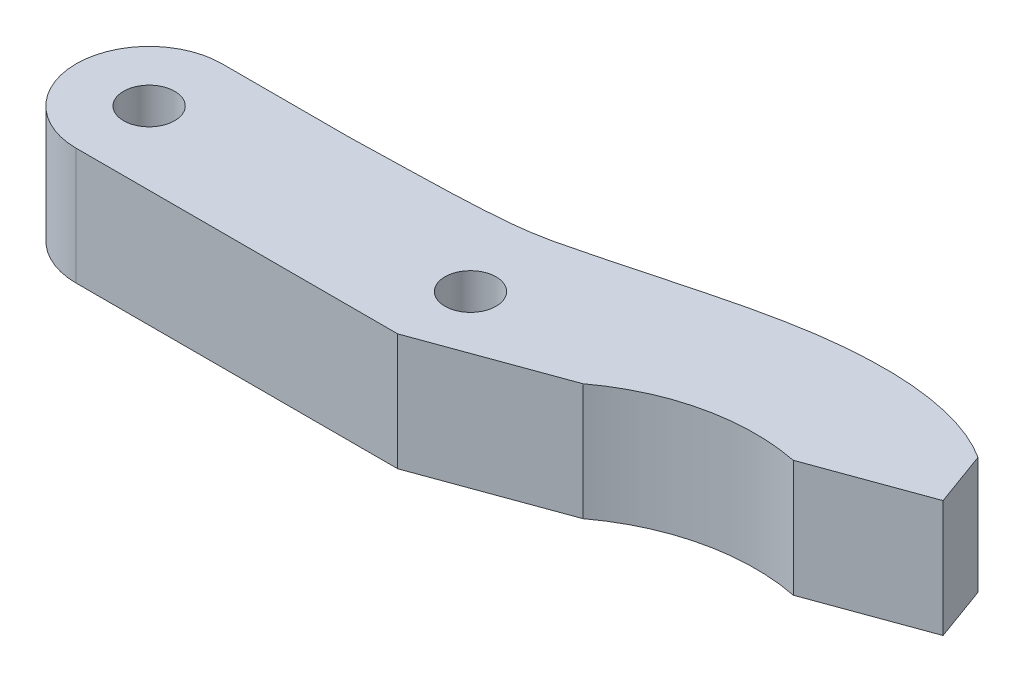
from build123d import *

# Parameters (mm, degrees)
IZIM1_R                     = 1.75
Y_KSEKLIK_EKSTR_ZYON1_DEPTH = 8


with BuildPart() as part:
    # Çizim1 → Yükseklik-Ekstrüzyon1 (new body)
    with BuildSketch(Plane(origin=(0, 0, 0), x_dir=(1, 0, 0), z_dir=(0, 1, 0))):
        with BuildLine():
            Line((0, -5), (22.015471808, -5))
            Line((22.015471808, -5), (31.318428753, -1.614000581))
            ThreePointArc((31.318428753, -1.614000581), (36.902874651, 0.961864866), (43.052194332, 1.045448688))
            Line((43.052194332, 1.045448688), (50.569735298, 3.781609835))
            Line((50.569735298, 3.781609835), (49.201654725, 7.540380318))
            add(Edge.make_bspline(
                [(8.7, 5), (11.831247013, 5.113252489), (19.015332027, 5.113410941), (26.701598214, 6.99026184), (30.566336288, 8.165203324), (40.878358811, 10.31583972), (46.259505748, 9.441547417), (49.201654725, 7.540380318)],
                knots=[0, 0, 0, 0, 0.110725447, 0.152620834, 0.389361308, 0.477058481, 1, 1, 1, 1], degree=3))
            Line((8.7, 5), (0, 5))
            ThreePointArc((0, 5), (-5, 0), (0, -5))
        make_face()
        Circle(IZIM1_R, mode=Mode.SUBTRACT)
        with Locations((22, 0)):
            Circle(IZIM1_R, mode=Mode.SUBTRACT)
    extrude(amount=Y_KSEKLIK_EKSTR_ZYON1_DEPTH)


solid = part.part
